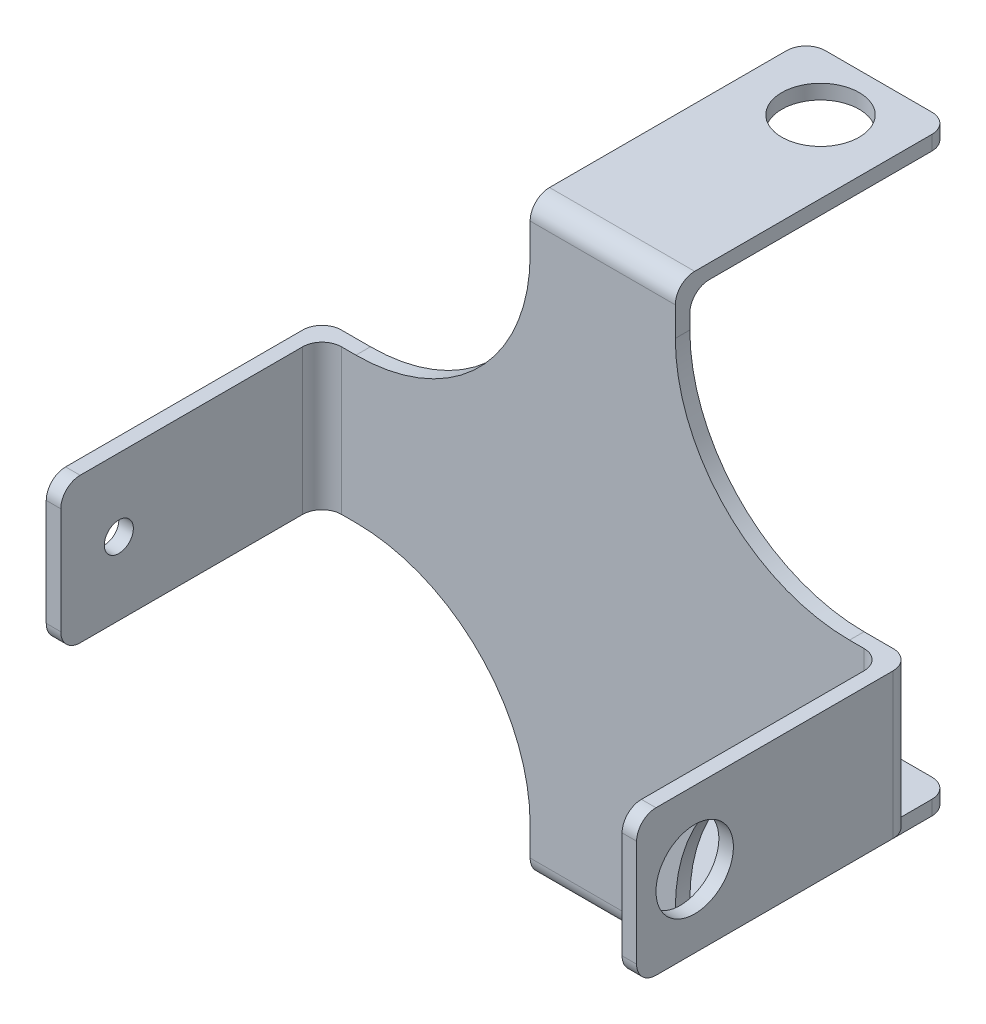
from build123d import *

# Parameters (mm, degrees)
SKETCH1_W           = 15
SKETCH1_H           = 21.5
SKETCH1_W_2         = 21.5
SKETCH1_H_2         = 15
BOSS_EXTRUDE1_DEPTH = 1.5
BOSS_EXTRUDE2_START = -1.5
SKETCH2_W           = 1.5
SKETCH2_H           = 15
BOSS_EXTRUDE2_DEPTH = 28.5
BOSS_EXTRUDE3_START = -1.5
SKETCH3_W           = 15
SKETCH3_H           = 1.5
BOSS_EXTRUDE3_DEPTH = 28.5
SKETCH4_R           = 1.5
CUT_EXTRUDE1_DEPTH  = 62
SKETCH5_R           = 1.5
CUT_EXTRUDE2_DEPTH  = 62
FILLET1_R           = 2
FILLET2_R           = 2
FILLET3_R           = 18
CUT_EXTRUDE3_REACH  = 63
SKETCH6_R           = 4
CUT_EXTRUDE4_REACH  = 63
SKETCH7_R           = 4


with BuildPart() as part:
    # Sketch1 → Boss-Extrude1 (new body)
    with BuildSketch(Plane.XY):
        with Locations((0, 18.25)):
            Rectangle(SKETCH1_W, SKETCH1_H)
        with Locations((-18.25, 0)):
            Rectangle(SKETCH1_W_2, SKETCH1_H_2)
        Rectangle(SKETCH1_W, SKETCH1_H_2)
        with Locations((18.25, 0)):
            Rectangle(SKETCH1_W_2, SKETCH1_H_2)
        with Locations((0, -18.25)):
            Rectangle(SKETCH1_W, SKETCH1_H)
    extrude(amount=BOSS_EXTRUDE1_DEPTH)

    # Sketch2 → Boss-Extrude2 (add)
    with BuildSketch(Plane.XY.offset(1.5).offset(BOSS_EXTRUDE2_START)):
        with Locations((-29.75, 0)):
            Rectangle(SKETCH2_W, SKETCH2_H)
        with Locations((29.75, 0)):
            Rectangle(SKETCH2_W, SKETCH2_H)
    extrude(amount=BOSS_EXTRUDE2_DEPTH)

    # Sketch3 → Boss-Extrude3 (add)
    with BuildSketch(Plane(origin=(0, 0, 0), x_dir=(-1, 0, 0), z_dir=(0, 0, -1)).offset(BOSS_EXTRUDE3_START)):
        with Locations((0, 29.75)):
            Rectangle(SKETCH3_W, SKETCH3_H)
        with Locations((0, -29.75)):
            Rectangle(SKETCH3_W, SKETCH3_H)
    extrude(amount=BOSS_EXTRUDE3_DEPTH)

    # Sketch4 → Cut-Extrude1 (cut, through all)
    with BuildSketch(Plane(origin=(30.5, 0, 0), x_dir=(0, 0, -1), z_dir=(1, 0, 0))):
        with Locations((-22.5, 0)):
            Circle(SKETCH4_R)
    extrude(amount=-CUT_EXTRUDE1_DEPTH, mode=Mode.SUBTRACT)

    # Sketch5 → Cut-Extrude2 (cut, through all)
    with BuildSketch(Plane(origin=(0, 30.5, 0), x_dir=(1, 0, 0), z_dir=(0, 1, 0))):
        with Locations((0, 21)):
            Circle(SKETCH5_R)
    extrude(amount=-CUT_EXTRUDE2_DEPTH, mode=Mode.SUBTRACT)

    # Fillet1
    fillet1_edges = [part.edges().sort_by_distance(p)[0] for p in [
        (-7.5, -29.75, -27),
        (7.5, -29.75, -27),
        (-7.5, 29.75, -27),
        (7.5, 29.75, -27),
        (-29.75, 7.5, 28.5),
        (-29.75, -7.5, 28.5),
        (29.75, -7.5, 28.5),
        (29.75, 7.5, 28.5),
    ]]
    fillet(fillet1_edges, radius=FILLET1_R)

    # Fillet2
    fillet2_edges = [part.edges().sort_by_distance(p)[0] for p in [
        (29, 0, 1.5),
        (30.5, 0, 0),
        (-30.5, 0, 0),
        (-29, 0, 1.5),
        (0, 29, 0),
        (0, -29, 0),
        (0, -30.5, 1.5),
        (0, 30.5, 1.5),
    ]]
    fillet(fillet2_edges, radius=FILLET2_R)

    # Fillet3
    fillet3_edges = [part.edges().sort_by_distance(p)[0] for p in [
        (-7.5, 7.5, 0.75),
        (-7.5, -7.5, 0.75),
        (7.5, -7.5, 0.75),
        (7.5, 7.5, 0.75),
    ]]
    fillet(fillet3_edges, radius=FILLET3_R)

    # Sketch6 → Cut-Extrude3 (cut, up to next)
    with BuildSketch(Plane(origin=(30.5, 0, 0), x_dir=(0, 0, -1), z_dir=(1, 0, 0)), mode=Mode.PRIVATE) as cut_extrude3_sk1:
        with Locations((-22.5, 0)):
            Circle(SKETCH6_R)
    cut_extrude3_tool1 = extrude(cut_extrude3_sk1.sketch, amount=-CUT_EXTRUDE3_REACH, mode=Mode.PRIVATE) & part.part
    add(cut_extrude3_tool1.solids().sort_by_distance((30.5, 0, 22.5))[0], mode=Mode.SUBTRACT)

    # Sketch7 → Cut-Extrude4 (cut, up to next)
    with BuildSketch(Plane(origin=(0, 30.5, 0), x_dir=(1, 0, 0), z_dir=(0, 1, 0)), mode=Mode.PRIVATE) as cut_extrude4_sk1:
        with Locations((0, 21)):
            Circle(SKETCH7_R)
    cut_extrude4_tool1 = extrude(cut_extrude4_sk1.sketch, amount=-CUT_EXTRUDE4_REACH, mode=Mode.PRIVATE) & part.part
    add(cut_extrude4_tool1.solids().sort_by_distance((0, 30.5, -21))[0], mode=Mode.SUBTRACT)


solid = part.part
